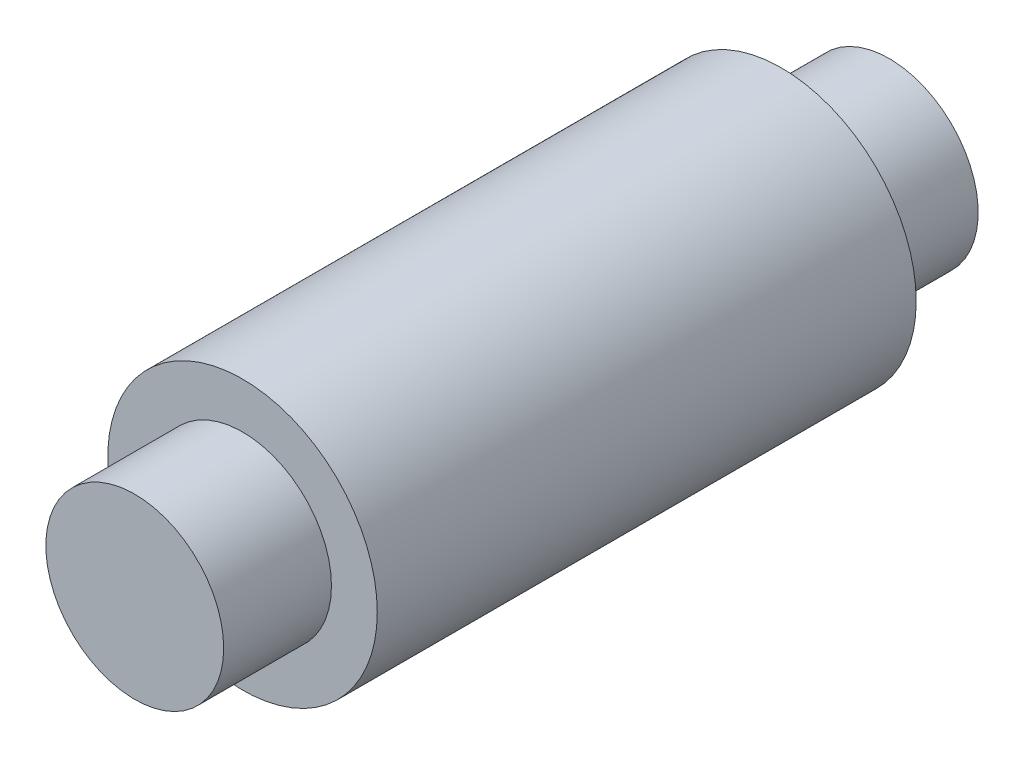
from build123d import *

# Parameters (mm, degrees)
ESQUISSE1_R        = 2.5
BOSS_EXTRU_1_DEPTH = 10
ESQUISSE2_R        = 1.65
BOSS_EXTRU_2_DEPTH = 2
ESQUISSE3_R        = 1.65
BOSS_EXTRU_3_DEPTH = 2


with BuildPart() as part:
    # Esquisse1 → Boss.-Extru.1 (new body)
    with BuildSketch(Plane.XY):
        Circle(ESQUISSE1_R)
    extrude(amount=BOSS_EXTRU_1_DEPTH)

    # Esquisse2 → Boss.-Extru.2 (add)
    with BuildSketch(Plane.XY.offset(10)):
        Circle(ESQUISSE2_R)
    extrude(amount=BOSS_EXTRU_2_DEPTH)

    # Esquisse3 → Boss.-Extru.3 (add)
    with BuildSketch(Plane(origin=(0, 0, 0), x_dir=(-1, 0, 0), z_dir=(0, 0, -1))):
        Circle(ESQUISSE3_R)
    extrude(amount=BOSS_EXTRU_3_DEPTH)


solid = part.part
